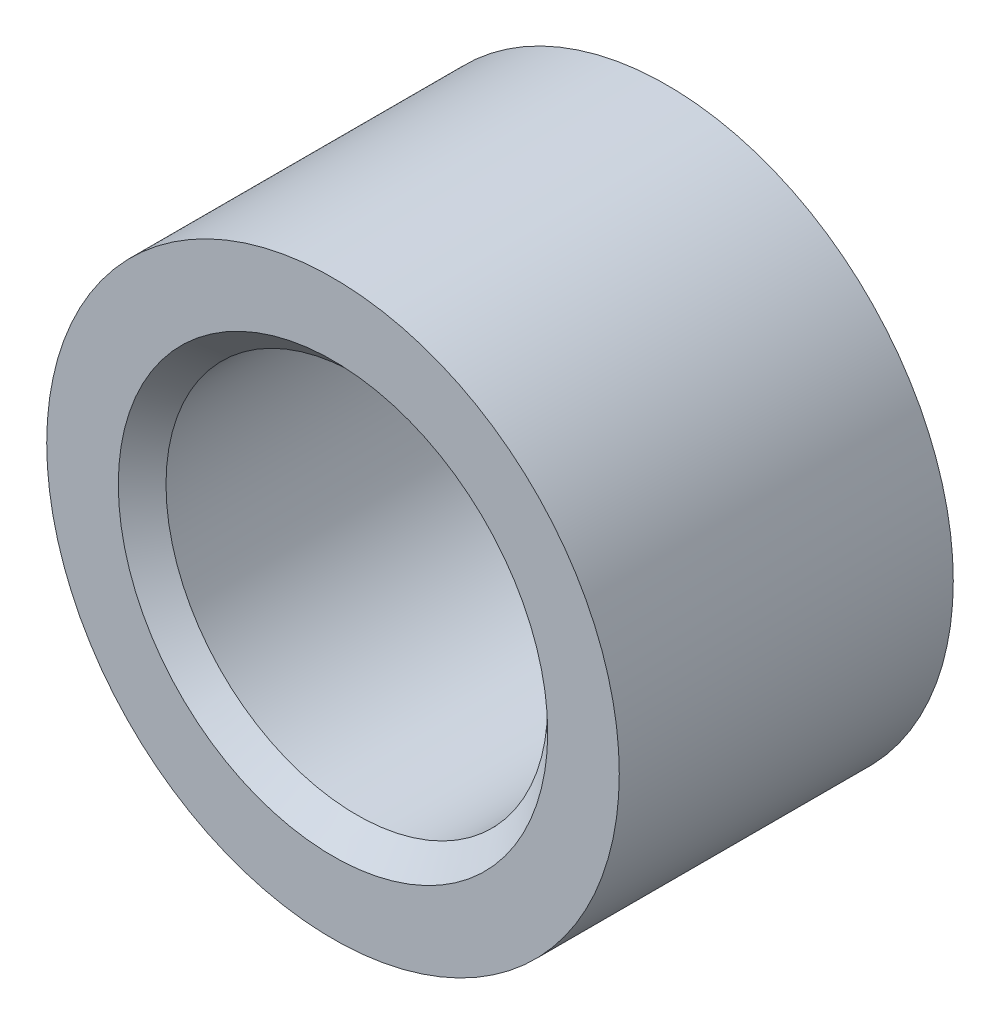
from build123d import *

# Parameters (mm, degrees)
SKETCH1_R           = 6
SKETCH1_R_2         = 4
BOSS_EXTRUDE1_DEPTH = 3.5
CHAMFER1_SIZE       = 0.5


with BuildPart() as part:
    # Sketch1 → Boss-Extrude1 (new body, symmetric)
    with BuildSketch(Plane.XY):
        Circle(SKETCH1_R)
        Circle(SKETCH1_R_2, mode=Mode.SUBTRACT)
    extrude(amount=BOSS_EXTRUDE1_DEPTH, both=True)

    # Chamfer1
    chamfer1_edges = [part.edges().sort_by_distance(p)[0] for p in [
        (-4, 0, -3.5),
        (-4, 0, 3.5),
    ]]
    chamfer(chamfer1_edges, length=CHAMFER1_SIZE)


solid = part.part
